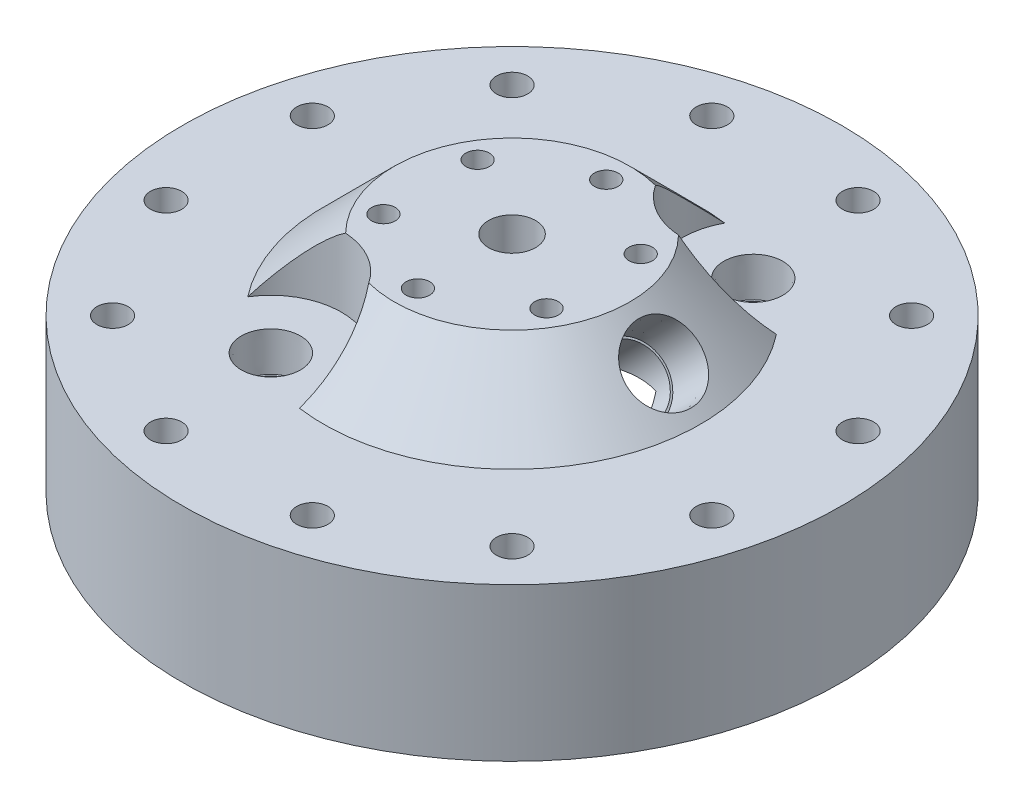
from build123d import *

# Parameters (mm, degrees)
F_5_16_CLEARANCE_HOLE1_D         = 8.4328
CIRPATTERN1_COUNT                = 12
F_1_2_0_5_DIAMETER_HOLE1_D       = 12.7
F_1_1_5_DIAMETER_HOLE1_D         = 38.1
F_1_1_5_DIAMETER_HOLE1_DEPTH     = 19.05
CIRPATTERN2_COUNT                = 6
CIRPATTERN3_COUNT                = 2
F_1_8_0_125_DIAMETER_HOLE1_D     = 3.175
F_1_8_0_125_DIAMETER_HOLE1_DEPTH = 6.35
F_1_8_0_125_DIAMETER_HOLE1_TIP   = 0.953866233


with BuildPart() as part:
    # Sketch1 → Revolve1 (revolve)
    with BuildSketch(Plane.XY, mode=Mode.PRIVATE) as revolve1_sk:
        Polygon((-88.9, 0), (-88.9, 41.275), (-50.8, 41.275), (-31.75, 60.325), (0, 60.325), (0, 34.925), (-31.75, 34.925), (-31.75, 22.225), (-50.8, 22.225), (-50.8, 3.175), (-52.3875, 3.175), (-52.3875, 5.715), (-55.9435, 5.715), (-55.9435, 3.175), (-57.15, 3.175), (-57.15, 0), align=None)
    revolve(revolve1_sk.sketch.rotate(Axis((0, 0, 0), (0, 1, 0)), 270), axis=Axis((0, 0, 0), (0, 1, 0)))

    # 5/16 Clearance Hole1 (through all)
    with Locations(Plane(origin=(0, 41.275, 0), x_dir=(1, 0, 0), z_dir=(0, 1, 0))):
        with Locations((-73.603547963, -19.722011237)):
            f_5_16_clearance_hole1 = Hole(F_5_16_CLEARANCE_HOLE1_D / 2)

    # CirPattern1: 5/16 Clearance Hole1 ×12 about axis
    cirpattern1_axis = Axis((0, 0, 0), (0, 1, 0))
    for i in range(1, CIRPATTERN1_COUNT):
        add(f_5_16_clearance_hole1.rotate(cirpattern1_axis, i * 360 / CIRPATTERN1_COUNT), mode=Mode.SUBTRACT)

    # 1/2 (0.5) Diameter Hole1 (through all)
    with Locations(Plane(origin=(0, 60.325, 0), x_dir=(1, 0, 0), z_dir=(0, 1, 0))):
        with Locations((0, 0)):
            Hole(F_1_2_0_5_DIAMETER_HOLE1_D / 2)

    # Sketch11 → 1/2 NPT Tapped Hole1 (revolve, cut)
    with BuildSketch(Plane(origin=(41.275, 50.8, 0), x_dir=(-0.707106781186546, 0.707106781186549, 0), z_dir=(0, 0, 1))):
        Polygon((0, 0), (0, 127.968649725), (8.9281, 127.968649725), (8.9281, 13.462), (9.479726792, 13.462), (9.8827971, 0), align=None)
    revolve(axis=Axis((45.765128061, 55.290128061, 0), (-0.707106781186549, -0.707106781186546, 0)), mode=Mode.SUBTRACT)

    # 1 (1.5) Diameter Hole1
    with Locations(Plane(origin=(0, 60.325, 0), x_dir=(1, 0, 0), z_dir=(0, 1, 0))):
        with Locations((-23.8125, -41.244459855)):
            f_1_1_5_diameter_hole1 = Hole(F_1_1_5_DIAMETER_HOLE1_D / 2, depth=F_1_1_5_DIAMETER_HOLE1_DEPTH)

    # Sketch19 → 3/8 NPT Tapped Hole1 (revolve, cut)
    with BuildSketch(Plane(origin=(-23.8125, 41.275, 41.244459855), x_dir=(0, 0, 1), z_dir=(1, 0, 0))):
        Polygon((0, 0), (0, 26.640582582), (7.1374, 22.352), (7.1374, 10.414), (7.653732494, 10.414), (7.9655416, 0), align=None)
    f_3_8_npt_tapped_hole1 = revolve(axis=Axis((-23.8125, 47.625, 41.244459855), (0, -1, 0)), mode=Mode.SUBTRACT)

    # Sketch21 → 1/4 (0.25) Diameter Hole1 (revolve, cut)
    with BuildSketch(Plane(origin=(21.997045256, 60.325, -12.7), x_dir=(0, 0, 1), z_dir=(1, 0, 0))):
        Polygon((0, 0), (0, 17.782732465), (3.175, 15.875), (3.175, 0), align=None)
    f_1_4_0_25_diameter_hole1 = revolve(axis=Axis((21.997045256, 66.675, -12.7), (0, -1, 0)), mode=Mode.SUBTRACT)

    # CirPattern2: 1/4 (0.25) Diameter Hole1 ×6 about axis
    cirpattern2_axis = Axis((0, 0, 0), (0, 1, 0))
    for i in range(1, CIRPATTERN2_COUNT):
        add(f_1_4_0_25_diameter_hole1.rotate(cirpattern2_axis, i * 360 / CIRPATTERN2_COUNT), mode=Mode.SUBTRACT)

    # CirPattern3: 1 (1.5) Diameter Hole1, 3/8 NPT Tapped Hole1 ×2 about axis
    cirpattern3_axis = Axis((0, 0, 0), (0, 1, 0))
    add([f_1_1_5_diameter_hole1.rotate(cirpattern3_axis, i * 360 / CIRPATTERN3_COUNT) for i in range(1, CIRPATTERN3_COUNT)], mode=Mode.SUBTRACT)
    add([f_3_8_npt_tapped_hole1.rotate(cirpattern3_axis, i * 360 / CIRPATTERN3_COUNT) for i in range(1, CIRPATTERN3_COUNT)], mode=Mode.SUBTRACT)

    # 1/8 (0.125) Diameter Hole1
    with Locations(Plane(origin=(0, 22.225, 0), x_dir=(-1, 0, 0), z_dir=(0, -1, 0))):
        with Locations((0, 44.45)):
            Hole(F_1_8_0_125_DIAMETER_HOLE1_D / 2, depth=F_1_8_0_125_DIAMETER_HOLE1_DEPTH)
            with Locations((0, 0, -(F_1_8_0_125_DIAMETER_HOLE1_DEPTH + F_1_8_0_125_DIAMETER_HOLE1_TIP / 2))):  # 118° drill point
                Cone(0, F_1_8_0_125_DIAMETER_HOLE1_D / 2, F_1_8_0_125_DIAMETER_HOLE1_TIP, mode=Mode.SUBTRACT)


solid = part.part
